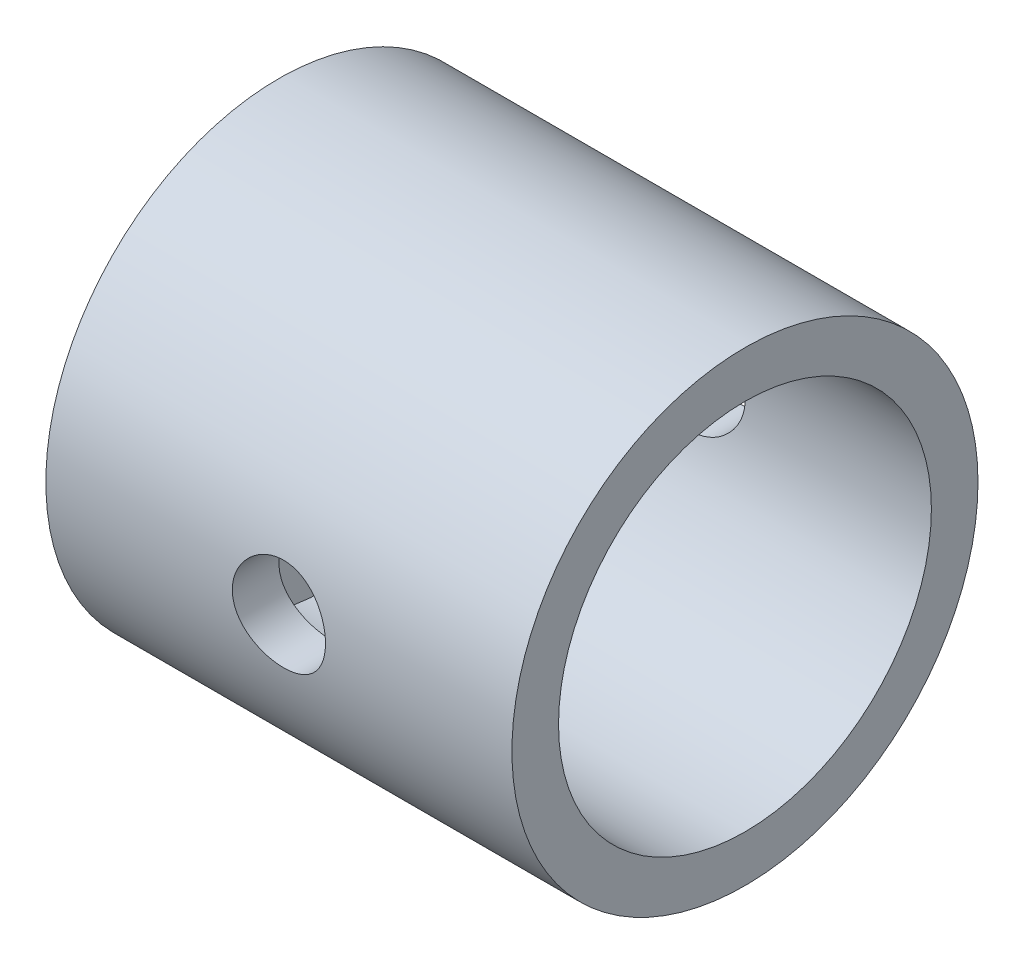
from build123d import *

# Parameters (mm, degrees)
SKETCH1_R               = 37.5
BOSS_EXTRUDE1_DEPTH     = 75
SHELL1_T                = -7.5
SKETCH2_R               = 7.5
CUT_EXTRUDE1_DEPTH      = 92.855865354
CUT_EXTRUDE1_DEPTH_BACK = 92.855865354


with BuildPart() as part:
    # Sketch1 → Boss-Extrude1 (new body)
    with BuildSketch(Plane(origin=(0, 0, 0), x_dir=(0, 0, -1), z_dir=(1, 0, 0))):
        Circle(SKETCH1_R)
    extrude(amount=BOSS_EXTRUDE1_DEPTH)

    # Shell1
    shell1_openings = [part.faces().sort_by_distance(p)[0] for p in [
        (75, 0, 0),
    ]]
    offset(amount=SHELL1_T, openings=shell1_openings, kind=Kind.INTERSECTION)

    # Sketch2 → Cut-Extrude1 (cut, two sides)
    with BuildSketch(Plane.XY) as cut_extrude1_sk:
        with Locations((37.5, 0)):
            Circle(SKETCH2_R)
    extrude(amount=CUT_EXTRUDE1_DEPTH, mode=Mode.SUBTRACT)
    extrude(cut_extrude1_sk.sketch, amount=-CUT_EXTRUDE1_DEPTH_BACK, mode=Mode.SUBTRACT)


solid = part.part
